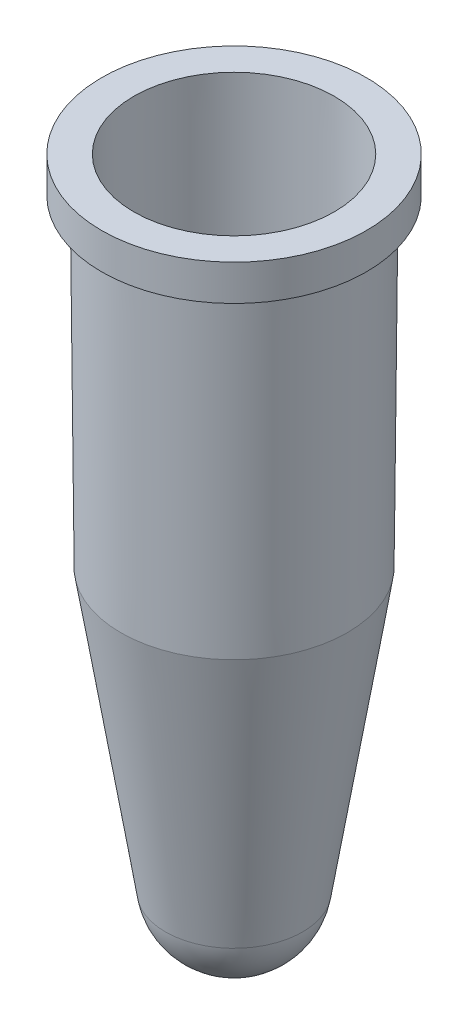
from build123d import *

# Parameters (mm, degrees)
SCALE1_SCALE = 0.85770751


with BuildPart() as part:
    # Sketch1 → Revolve25 (revolve)
    with BuildSketch(Plane.XY):
        with BuildLine():
            Line((-5.582614804, -1.992146118), (-5.6, 0))
            Line((-5.6, 0), (-7.4, 0))
            Line((-7.4, 0), (-7.4, -2))
            Line((-7.4, -2), (-6.482580535, -2))
            Line((-6.482580535, -2), (-6.325496915, -20))
            Line((-6.325496915, -20), (-3.834959356, -35.724635285))
            ThreePointArc((-3.834959356, -35.724635285), (-2.521652597, -38.069713242), (0, -39))
            Line((0, -39), (0, -38.1))
            ThreePointArc((0, -38.1), (-1.937149354, -37.385347873), (-2.946039849, -35.583844266))
            Line((-2.946039849, -35.583844266), (-5.426114828, -19.925267112))
            Line((-5.426114828, -19.925267112), (-5.582614804, -1.992146118))
        make_face()
    revolve(axis=Axis((0, 0, 0), (0, -1, 0)))


with BuildPart() as part_1:
    # Scale1: scaled about (0, -16.444791582, 0)
    add(part.part.scale(SCALE1_SCALE).moved(Location((0, -2.339970344, 0))))


solid = part_1.part
